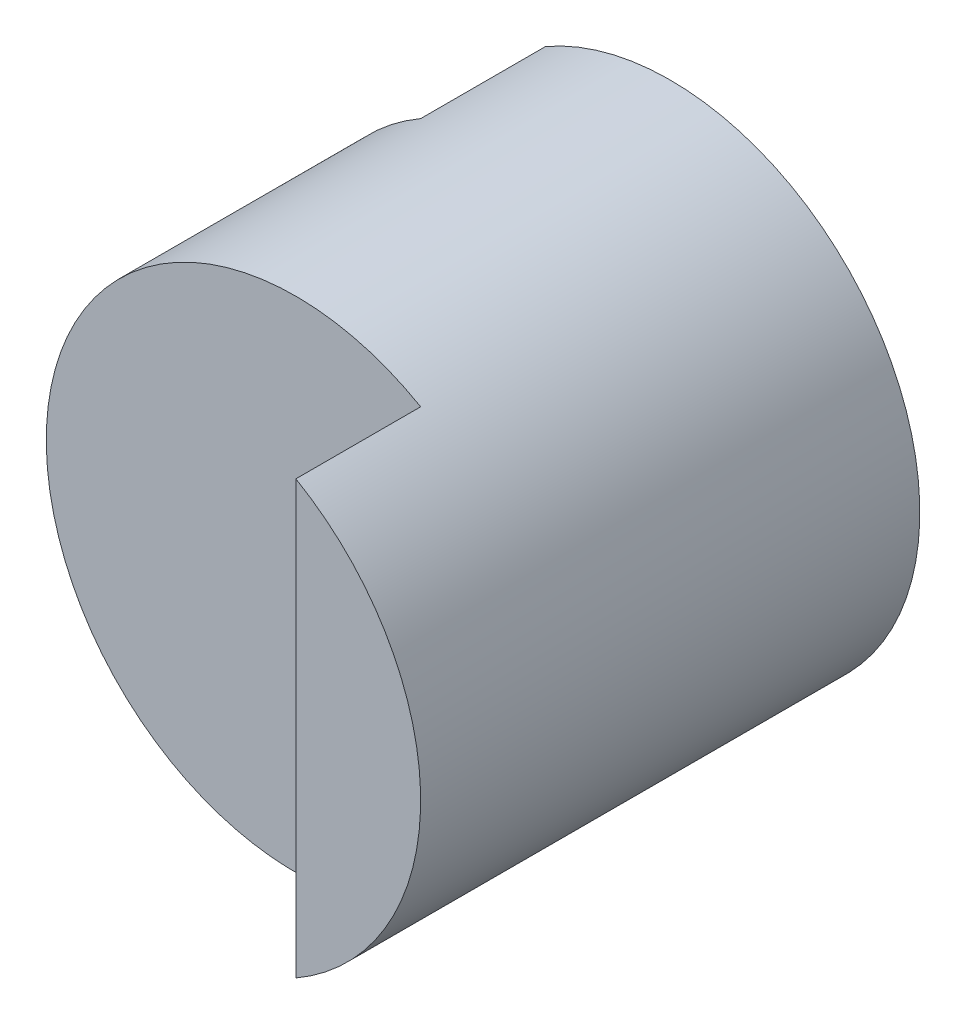
from build123d import *

# Parameters (mm, degrees)
SKETCH1_R               = 20
BOSS_EXTRUDE1_DEPTH     = 40
CUT_EXTRUDE1_DEPTH      = 40
CUT_EXTRUDE1_DEPTH_BACK = 40
SKETCH2_W               = 30
SKETCH2_H               = 10
SKETCH2_W_2             = 10


with BuildPart() as part:
    # Sketch1 → Boss-Extrude1 (new body)
    with BuildSketch(Plane.XY):
        Circle(SKETCH1_R)
    extrude(amount=BOSS_EXTRUDE1_DEPTH)

    # Sketch2 → Cut-Extrude1 (cut, two sides: drawn at the far end of the back side and taken through both)
    with BuildSketch(Plane(origin=(0, 0, 0), x_dir=(1, 0, 0), z_dir=(0, 1, 0)).offset(-CUT_EXTRUDE1_DEPTH_BACK)):
        with Locations((-5, -35)):
            Rectangle(SKETCH2_W, SKETCH2_H)
        with Locations((-15, -5)):
            Rectangle(SKETCH2_W_2, SKETCH2_H)
    extrude(amount=CUT_EXTRUDE1_DEPTH + CUT_EXTRUDE1_DEPTH_BACK, mode=Mode.SUBTRACT)


solid = part.part
